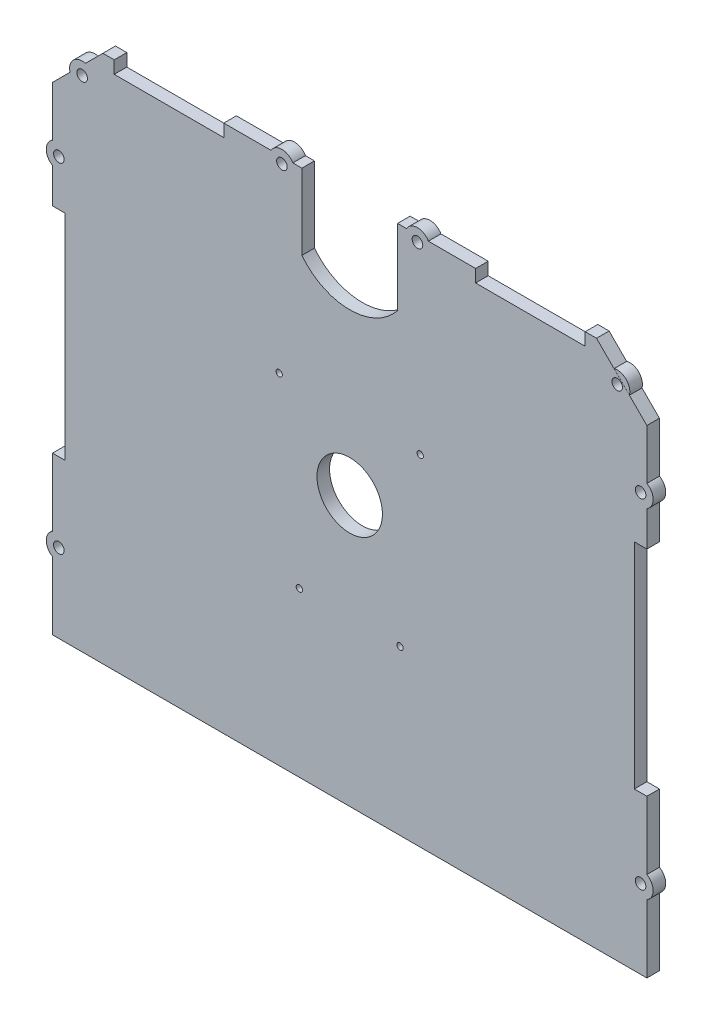
from build123d import *

# Parameters (mm, degrees)
BOSS_EXTRUDE1_DEPTH     = 5
SKETCH4_W               = 5
SKETCH4_H               = 85
CUT_EXTRUDE3_DEPTH      = 6
SKETCH5_W               = 43.5
SKETCH5_H               = 5
CUT_EXTRUDE4_DEPTH      = 5
SKETCH6_R               = 2.1
CUT_EXTRUDE5_DEPTH      = 5
BOSS_EXTRUDE2_DEPTH     = 5
SKETCH8_R               = 13
CUT_EXTRUDE6_DEPTH      = 5
SKETCH9_R               = 1.25
CUT_EXTRUDE7_DEPTH      = 5
CUT_EXTRUDE8_DEPTH      = 1
CUT_EXTRUDE8_DEPTH_BACK = 5


with BuildPart() as part:
    # Sketch1 → Boss-Extrude1 (new body)
    with BuildSketch(Plane.XY):
        Polygon((64.226162893, -107), (118, -107), (118, 83), (98, 103), (-98, 103), (-118, 83), (-118, -107), (-64.226162893, -107), align=None)
    extrude(amount=BOSS_EXTRUDE1_DEPTH)

    # Sketch4 → Cut-Extrude3 (cut, through all)
    with BuildSketch(Plane.XY.offset(5)):
        with Locations((-115.5, -2)):
            Rectangle(SKETCH4_W, SKETCH4_H)
        with Locations((115.5, -2)):
            Rectangle(SKETCH4_W, SKETCH4_H)
    extrude(amount=-CUT_EXTRUDE3_DEPTH, mode=Mode.SUBTRACT)

    # Sketch5 → Cut-Extrude4 (cut)
    with BuildSketch(Plane.XY.offset(5)):
        with Locations((71.75, 100.5)):
            Rectangle(SKETCH5_W, SKETCH5_H)
        with Locations((-71.75, 100.5)):
            Rectangle(SKETCH5_W, SKETCH5_H)
    extrude(amount=-CUT_EXTRUDE4_DEPTH, mode=Mode.SUBTRACT)

    # Sketch6 → Cut-Extrude5 (cut)
    with BuildSketch(Plane.XY.offset(5)):
        with Locations((-106.232988104, 91.23147799)):
            Circle(SKETCH6_R)
        with Locations((106.232988104, 91.23147799)):
            Circle(SKETCH6_R)
        with Locations((115.5, 58.75)):
            Circle(SKETCH6_R)
        with Locations((115.5, -75.75)):
            Circle(SKETCH6_R)
        with Locations((-115.5, 58.75)):
            Circle(SKETCH6_R)
        with Locations((-115.5, -75.75)):
            Circle(SKETCH6_R)
        with Locations((-26.91, 100.5)):
            Circle(SKETCH6_R)
        with Locations((26.91, 100.5)):
            Circle(SKETCH6_R)
    extrude(amount=-CUT_EXTRUDE5_DEPTH, mode=Mode.SUBTRACT)

    # Sketch7 → Boss-Extrude2 (add)
    with BuildSketch(Plane.XY.offset(5)):
        with BuildLine():
            Line((-104.938892879, 96.061107121), (-111.062617235, 89.937382765))
            ThreePointArc((-111.062617235, 89.937382765), (-109.76852201, 94.767011896), (-104.938892879, 96.061107121))
        make_face()
        with BuildLine():
            Line((-118, 63.080127019), (-118, 54.419872981))
            ThreePointArc((-118, 54.419872981), (-120.5, 58.75), (-118, 63.080127019))
        make_face()
        with BuildLine():
            Line((-118, -71.419872981), (-118, -80.080127019))
            ThreePointArc((-118, -80.080127019), (-120.5, -75.75), (-118, -71.419872981))
        make_face()
        with BuildLine():
            Line((118, -71.419872981), (118, -80.080127019))
            ThreePointArc((118, -80.080127019), (120.5, -75.75), (118, -71.419872981))
        make_face()
        with BuildLine():
            Line((111.062617235, 89.937382765), (104.999243157, 96.076875126))
            ThreePointArc((104.999243157, 96.076875126), (109.790506534, 94.74488981), (111.062617235, 89.937382765))
        make_face()
        with BuildLine():
            Line((118, 54.419872981), (118, 63.080127019))
            ThreePointArc((118, 63.080127019), (120.5, 58.75), (118, 54.419872981))
        make_face()
        with BuildLine():
            Line((22.579872981, 103), (31.240127019, 103))
            ThreePointArc((31.240127019, 103), (26.91, 105.5), (22.579872981, 103))
        make_face()
        with BuildLine():
            Line((-31.240127019, 103), (-22.579872981, 103))
            ThreePointArc((-22.579872981, 103), (-26.91, 105.5), (-31.240127019, 103))
        make_face()
    extrude(amount=-BOSS_EXTRUDE2_DEPTH)

    # Sketch8 → Cut-Extrude6 (cut)
    with BuildSketch(Plane.XY.offset(5)):
        Circle(SKETCH8_R)
    extrude(amount=-CUT_EXTRUDE6_DEPTH, mode=Mode.SUBTRACT)

    # Sketch9 → Cut-Extrude7 (cut)
    with BuildSketch(Plane.XY.offset(5)):
        with Locations((28, 28)):
            Circle(SKETCH9_R)
        with Locations((20, -42)):
            Circle(SKETCH9_R)
        with Locations((-20, -42)):
            Circle(SKETCH9_R)
        with Locations((-28, 28)):
            Circle(SKETCH9_R)
    extrude(amount=-CUT_EXTRUDE7_DEPTH, mode=Mode.SUBTRACT)

    # Sketch10 → Cut-Extrude8 (cut, two sides)
    with BuildSketch(Plane.XY.offset(5)) as cut_extrude8_sk:
        with BuildLine():
            Line((19, 73), (19, 103))
            Line((19, 103), (-19, 103))
            Line((-19, 103), (-19, 73))
            ThreePointArc((-19, 73), (0, 63.792563126), (19, 73))
        make_face()
    extrude(amount=CUT_EXTRUDE8_DEPTH, mode=Mode.SUBTRACT)
    extrude(cut_extrude8_sk.sketch, amount=-CUT_EXTRUDE8_DEPTH_BACK, mode=Mode.SUBTRACT)


solid = part.part
